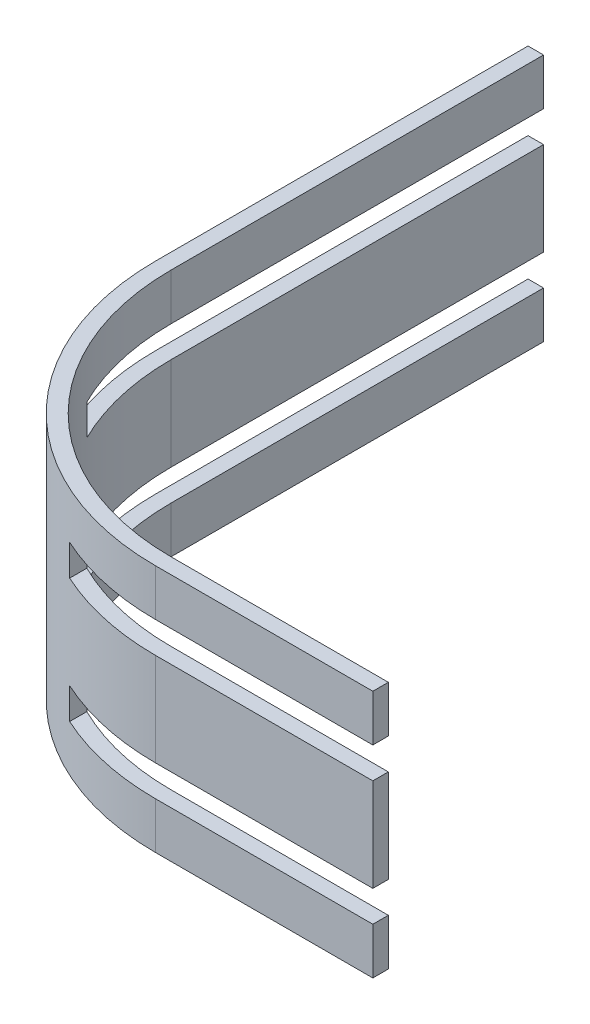
from build123d import *

# Parameters (mm, degrees)
EXTRUDE1_DEPTH = 6
EXTRUDE2_DEPTH = 2
EXTRUDE3_START = 2
EXTRUDE3_DEPTH = 2
EXTRUDE4_DEPTH = 3
EXTRUDE5_START = 3
EXTRUDE5_DEPTH = 3


with BuildPart() as part:
    # Sketch1 → Extrude1 (new body)
    with BuildSketch(Plane(origin=(0, 0, 0), x_dir=(1, 0, 0), z_dir=(0, 1, 0))):
        with BuildLine():
            Line((-15, 20), (-15, -4))
            ThreePointArc((-15, -4), (-10.313708499, -15.313708499), (1, -20))
            Line((1, -20), (15, -20))
            Line((15, -20), (15, -21))
            Line((15, -21), (1, -21))
            ThreePointArc((1, -21), (-11.02081528, -16.02081528), (-16, -4))
            Line((-16, -4), (-16, 20))
            Line((-16, 20), (-15, 20))
        make_face()
    extrude(amount=EXTRUDE1_DEPTH)

    # Sketch2 → Extrude2 (add)
    with BuildSketch(Plane(origin=(0, 6, 0), x_dir=(1, 0, 0), z_dir=(0, 1, 0))):
        with BuildLine():
            Line((-6.075, -18.350762175), (-6.075, -19.457825688))
            ThreePointArc((-6.075, -19.457825688), (-11.02081528, -16.02081528), (-14.457825688, -11.075))
            Line((-14.457825688, -11.075), (-13.350762175, -11.075))
            ThreePointArc((-13.350762175, -11.075), (-10.313708499, -15.313708499), (-6.075, -18.350762175))
        make_face()
    extrude(amount=EXTRUDE2_DEPTH)

    # Sketch3 → Extrude3 (add)
    with BuildSketch(Plane.XZ.offset(EXTRUDE3_START)):
        with BuildLine():
            Line((-14.457825688, 11.075), (-13.350762175, 11.075))
            ThreePointArc((-13.350762175, 11.075), (-10.313708499, 15.313708499), (-6.075, 18.350762175))
            Line((-6.075, 18.350762175), (-6.075, 19.457825688))
            ThreePointArc((-6.075, 19.457825688), (-11.02081528, 16.02081528), (-14.457825688, 11.075))
        make_face()
    extrude(amount=-EXTRUDE3_DEPTH)

    # Sketch4 → Extrude4 (add)
    with BuildSketch(Plane(origin=(0, 8, 0), x_dir=(1, 0, 0), z_dir=(0, 1, 0))):
        with BuildLine():
            Line((15, -21), (15, -20))
            Line((15, -20), (1, -20))
            ThreePointArc((1, -20), (-2.632341201, -19.582236598), (-6.075, -18.350762175))
            ThreePointArc((-6.075, -18.350762175), (-10.313708499, -15.313708499), (-13.350762175, -11.075))
            ThreePointArc((-13.350762175, -11.075), (-14.582236598, -7.632341201), (-15, -4))
            Line((-15, -4), (-15, 20))
            Line((-15, 20), (-16, 20))
            Line((-16, 20), (-16, -4))
            ThreePointArc((-16, -4), (-15.609982491, -7.62056372), (-14.457825688, -11.075))
            ThreePointArc((-14.457825688, -11.075), (-11.02081528, -16.02081528), (-6.075, -19.457825688))
            ThreePointArc((-6.075, -19.457825688), (-2.62056372, -20.609982491), (1, -21))
            Line((1, -21), (15, -21))
        make_face()
    extrude(amount=EXTRUDE4_DEPTH)

    # Sketch5 → Extrude5 (add)
    with BuildSketch(Plane.XZ.offset(2).offset(EXTRUDE5_START)):
        with BuildLine():
            Line((-16, -20), (-16, 4))
            ThreePointArc((-16, 4), (-15.609982491, 7.62056372), (-14.457825688, 11.075))
            ThreePointArc((-14.457825688, 11.075), (-11.02081528, 16.02081528), (-6.075, 19.457825688))
            ThreePointArc((-6.075, 19.457825688), (-2.62056372, 20.609982491), (1, 21))
            Line((1, 21), (15, 21))
            Line((15, 21), (15, 20))
            Line((15, 20), (1, 20))
            ThreePointArc((1, 20), (-2.632341201, 19.582236598), (-6.075, 18.350762175))
            ThreePointArc((-6.075, 18.350762175), (-10.313708499, 15.313708499), (-13.350762175, 11.075))
            ThreePointArc((-13.350762175, 11.075), (-14.582236598, 7.632341201), (-15, 4))
            Line((-15, 4), (-15, -20))
            Line((-15, -20), (-16, -20))
        make_face()
    extrude(amount=-EXTRUDE5_DEPTH)


solid = part.part
